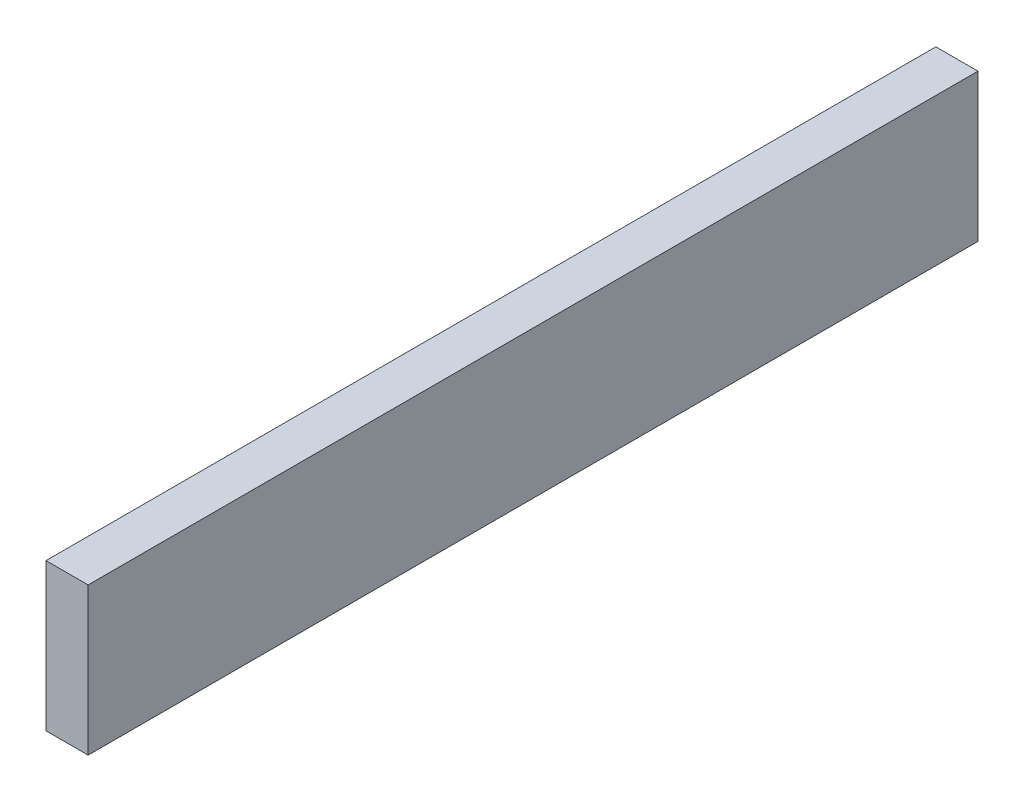
from build123d import *

# Parameters (mm, degrees)
SKETCH1_W           = 84.5
SKETCH1_H           = 14
BOSS_EXTRUDE1_DEPTH = 4


with BuildPart() as part:
    # Sketch1 → Boss-Extrude1 (new body)
    with BuildSketch(Plane(origin=(0, 0, 0), x_dir=(0, 0, -1), z_dir=(1, 0, 0))):
        Rectangle(SKETCH1_W, SKETCH1_H)
    extrude(amount=-BOSS_EXTRUDE1_DEPTH)


solid = part.part
